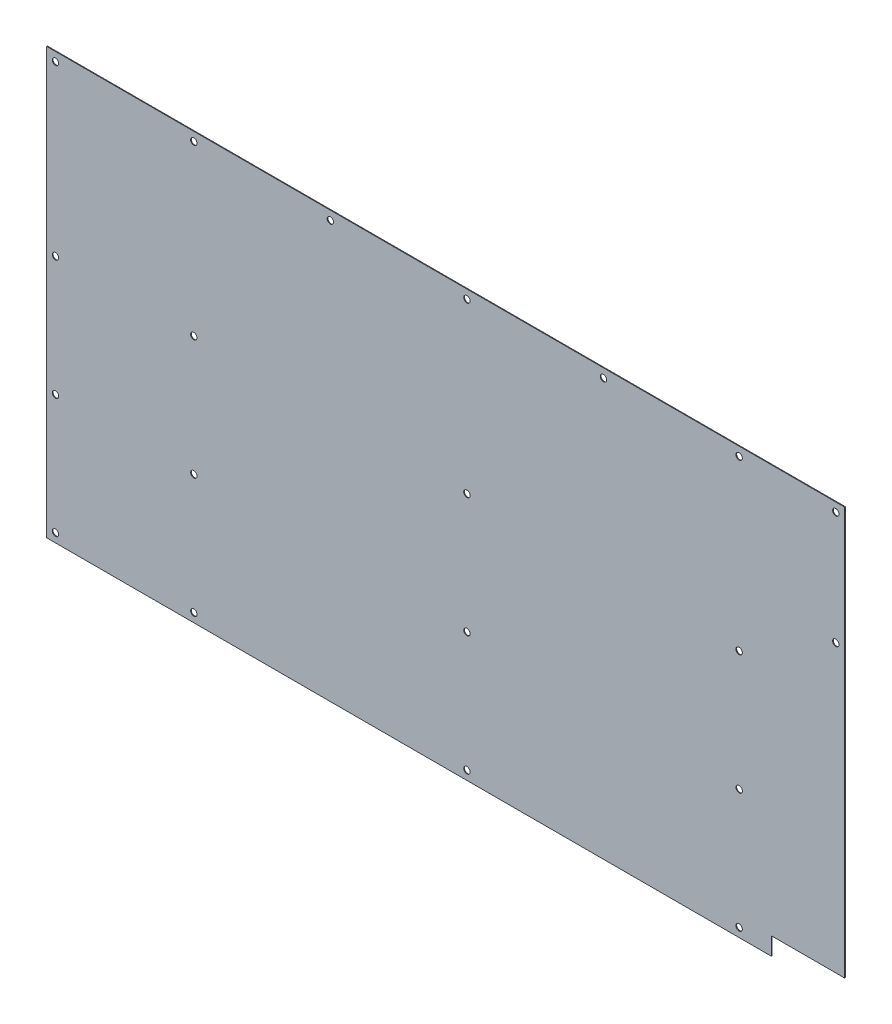
from build123d import *

# Parameters (mm, degrees)
MODEL_R             = 1.8288
BOSS_EXTRUDE2_DEPTH = 0.4064


with BuildPart() as part:
    # Model → Boss-Extrude2 (new body)
    with BuildSketch(Plane.XY):
        with BuildLine():
            Line((0, 243.7765), (0, 0))
            Line((0, 0), (415.2265, 0))
            ThreePointArc((415.2265, 0), (415.245098719, 0.044901281), (415.29, 0.0635))
            Line((415.29, 0.0635), (415.29, 10.0965))
            ThreePointArc((415.29, 10.0965), (415.245098719, 10.204901281), (415.3535, 10.16))
            Line((415.3535, 10.16), (457.1365, 10.16))
            ThreePointArc((457.1365, 10.16), (457.155098719, 10.204901281), (457.2, 10.2235))
            Line((457.2, 10.2235), (457.2, 243.7765))
            ThreePointArc((457.2, 243.7765), (457.155098719, 243.795098719), (457.1365, 243.84))
            Line((457.1365, 243.84), (0.0635, 243.84))
            ThreePointArc((0.0635, 243.84), (0.044901281, 243.795098719), (0, 243.7765))
        make_face()
        with Locations((5.08, 5.08)):
            Circle(MODEL_R, mode=Mode.SUBTRACT)
        with Locations((84.328, 5.08)):
            Circle(MODEL_R, mode=Mode.SUBTRACT)
        with Locations((5.08, 73.66)):
            Circle(MODEL_R, mode=Mode.SUBTRACT)
        with Locations((84.328, 73.66)):
            Circle(MODEL_R, mode=Mode.SUBTRACT)
        with Locations((240.792, 5.08)):
            Circle(MODEL_R, mode=Mode.SUBTRACT)
        with Locations((396.748, 5.08)):
            Circle(MODEL_R, mode=Mode.SUBTRACT)
        with Locations((240.792, 73.66)):
            Circle(MODEL_R, mode=Mode.SUBTRACT)
        with Locations((396.748, 73.66)):
            Circle(MODEL_R, mode=Mode.SUBTRACT)
        with Locations((5.08, 142.24)):
            Circle(MODEL_R, mode=Mode.SUBTRACT)
        with Locations((84.328, 142.24)):
            Circle(MODEL_R, mode=Mode.SUBTRACT)
        with Locations((5.08, 238.76)):
            Circle(MODEL_R, mode=Mode.SUBTRACT)
        with Locations((84.328, 238.76)):
            Circle(MODEL_R, mode=Mode.SUBTRACT)
        with Locations((162.56, 238.76)):
            Circle(MODEL_R, mode=Mode.SUBTRACT)
        with Locations((240.792, 142.24)):
            Circle(MODEL_R, mode=Mode.SUBTRACT)
        with Locations((396.748, 142.24)):
            Circle(MODEL_R, mode=Mode.SUBTRACT)
        with Locations((452.12, 173.99)):
            Circle(MODEL_R, mode=Mode.SUBTRACT)
        with Locations((240.792, 238.76)):
            Circle(MODEL_R, mode=Mode.SUBTRACT)
        with Locations((319.024, 238.76)):
            Circle(MODEL_R, mode=Mode.SUBTRACT)
        with Locations((396.748, 238.76)):
            Circle(MODEL_R, mode=Mode.SUBTRACT)
        with Locations((452.12, 238.76)):
            Circle(MODEL_R, mode=Mode.SUBTRACT)
    extrude(amount=BOSS_EXTRUDE2_DEPTH)


solid = part.part
